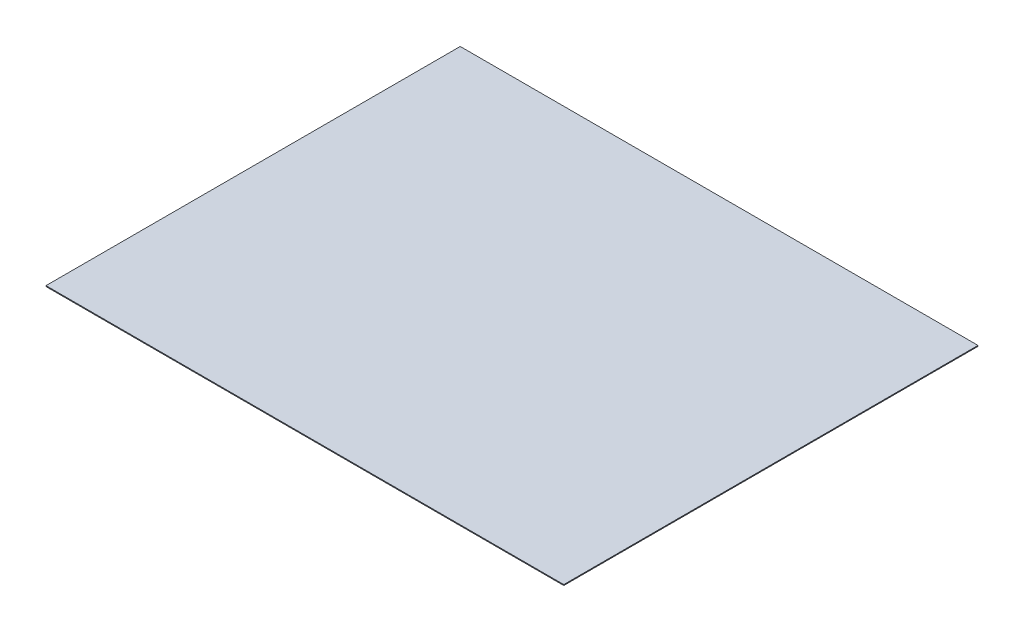
from build123d import *

# Parameters (mm, degrees)
SKETCH1_W           = 1524
SKETCH1_H           = 1219.2
BOSS_EXTRUDE1_DEPTH = 2.54


with BuildPart() as part:
    # Sketch1 → Boss-Extrude1 (new body)
    with BuildSketch(Plane(origin=(0, 0, 0), x_dir=(1, 0, 0), z_dir=(0, 1, 0))):
        with Locations((168.875675676, -411.891891892)):
            Rectangle(SKETCH1_W, SKETCH1_H)
    extrude(amount=BOSS_EXTRUDE1_DEPTH)


solid = part.part
